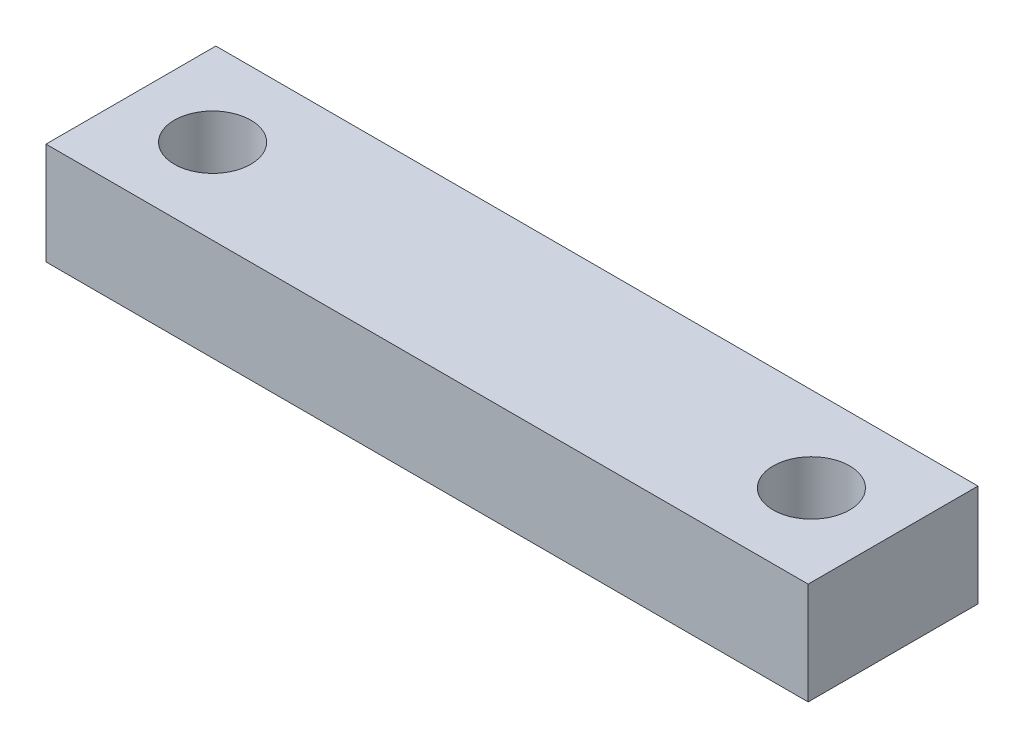
from build123d import *

# Parameters (mm, degrees)
SKETCH1_W                    = 71.12
SKETCH1_H                    = 15.8496
BOSS_EXTRUDE1_DEPTH          = 9.525
K_0_281_DIAMETER_HOLE1_D     = 7.1374
K_0_281_DIAMETER_HOLE1_DEPTH = 9.525


with BuildPart() as part:
    # Sketch1 → Boss-Extrude1 (new body)
    with BuildSketch(Plane(origin=(0, 0, 0), x_dir=(1, 0, 0), z_dir=(0, 1, 0))):
        Rectangle(SKETCH1_W, SKETCH1_H)
    extrude(amount=BOSS_EXTRUDE1_DEPTH)

    # K (0.281) Diameter Hole1
    with Locations(Plane(origin=(0, 9.525, 0), x_dir=(1, 0, 0), z_dir=(0, 1, 0))):
        with Locations((-27.94, 0), (27.94, 0)):
            Hole(K_0_281_DIAMETER_HOLE1_D / 2, depth=K_0_281_DIAMETER_HOLE1_DEPTH)


solid = part.part
